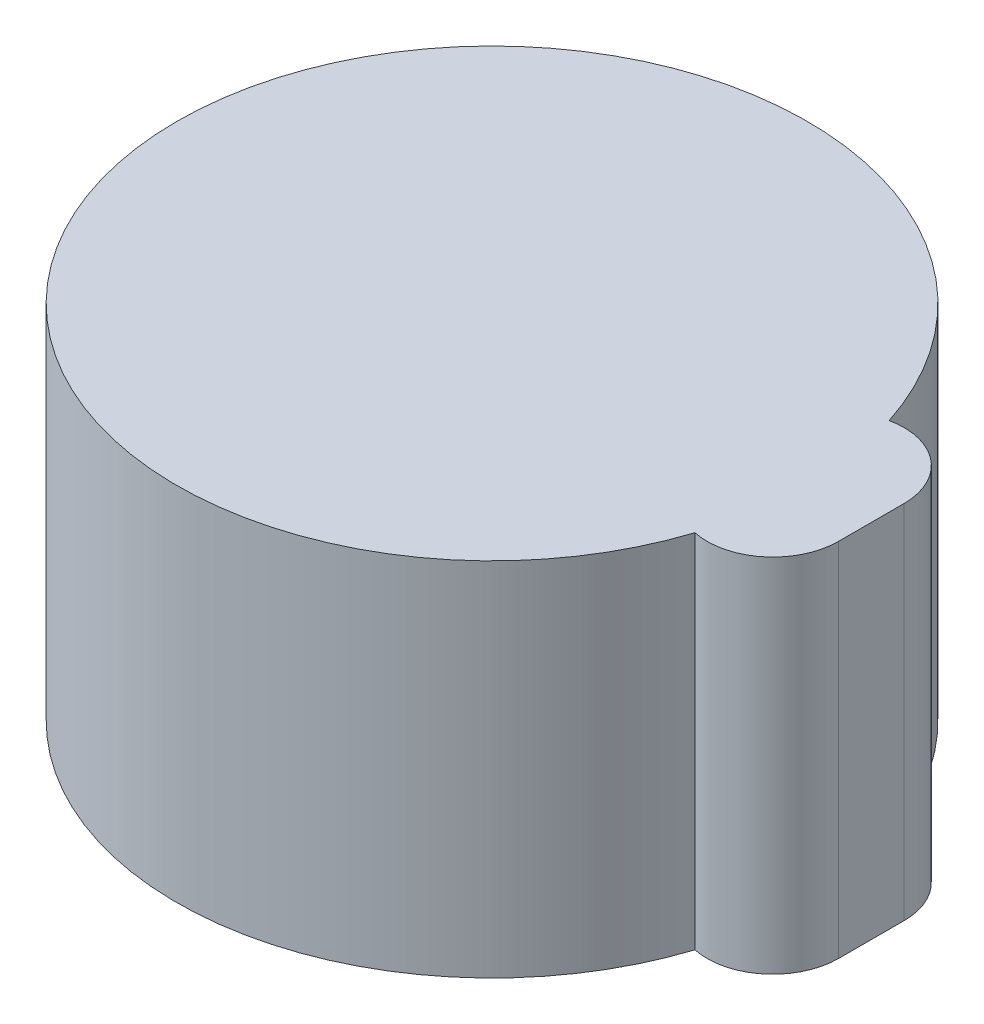
from build123d import *

# Parameters (mm, degrees)
BOSS_EXTRUDE1_DEPTH = 5
BOSS_EXTRUDE2_DEPTH = 0.5
BOSS_EXTRUDE3_DEPTH = 1


with BuildPart() as part:
    # Sketch1 → Boss-Extrude1 (new body)
    with BuildSketch(Plane(origin=(0, 0, 0), x_dir=(1, 0, 0), z_dir=(0, 1, 0))):
        with BuildLine():
            ThreePointArc((4.566687335, 1.478298611), (-4.8, 0), (4.566687335, -1.478298611))
            ThreePointArc((4.566687335, -1.478298611), (5.403490366, -1.276916974), (5.773887305, -0.5))
            Line((5.773887305, -0.5), (5.773887305, 0.5))
            ThreePointArc((5.773887305, 0.5), (5.403490366, 1.276916974), (4.566687335, 1.478298611))
        make_face()
        with BuildLine():
            ThreePointArc((5.273887305, -0.5), (5.098728559, -0.880102828), (4.695974666, -0.993892317))
            Line((4.695974666, -0.993892317), (4.183560453, -0.993892317))
            ThreePointArc((4.183560453, -0.993892317), (-4.3, 0), (4.183560453, 0.993892317))
            Line((4.183560453, 0.993892317), (4.695974666, 0.993892317))
            ThreePointArc((4.695974666, 0.993892317), (5.098728559, 0.880102828), (5.273887305, 0.5))
            Line((5.273887305, 0.5), (5.273887305, -0.5))
        make_face(mode=Mode.SUBTRACT)
    extrude(amount=BOSS_EXTRUDE1_DEPTH)

    # Sketch3 → Boss-Extrude2 (add)
    with BuildSketch(Plane(origin=(0, 5, 0), x_dir=(1, 0, 0), z_dir=(0, 1, 0))):
        with BuildLine():
            Line((5.773887305, -0.5), (5.773887305, 0.5))
            ThreePointArc((5.773887305, 0.5), (5.403490366, 1.276916974), (4.566687335, 1.478298611))
            ThreePointArc((4.566687335, 1.478298611), (-4.8, 0), (4.566687335, -1.478298611))
            ThreePointArc((4.566687335, -1.478298611), (5.403490366, -1.276916974), (5.773887305, -0.5))
        make_face()
    extrude(amount=BOSS_EXTRUDE2_DEPTH)

    # Sketch4 → Boss-Extrude3 (add)
    with BuildSketch(Plane.XZ.offset(-5)):
        with BuildLine():
            Line((3.667721099, 0.993892317), (4.183560453, 0.993892317))
            ThreePointArc((4.183560453, 0.993892317), (-4.3, 0), (4.183560453, -0.993892317))
            Line((4.183560453, -0.993892317), (3.667721099, -0.993892317))
            ThreePointArc((3.667721099, -0.993892317), (-3.8, 0), (3.667721099, 0.993892317))
        make_face()
    extrude(amount=BOSS_EXTRUDE3_DEPTH)


solid = part.part
